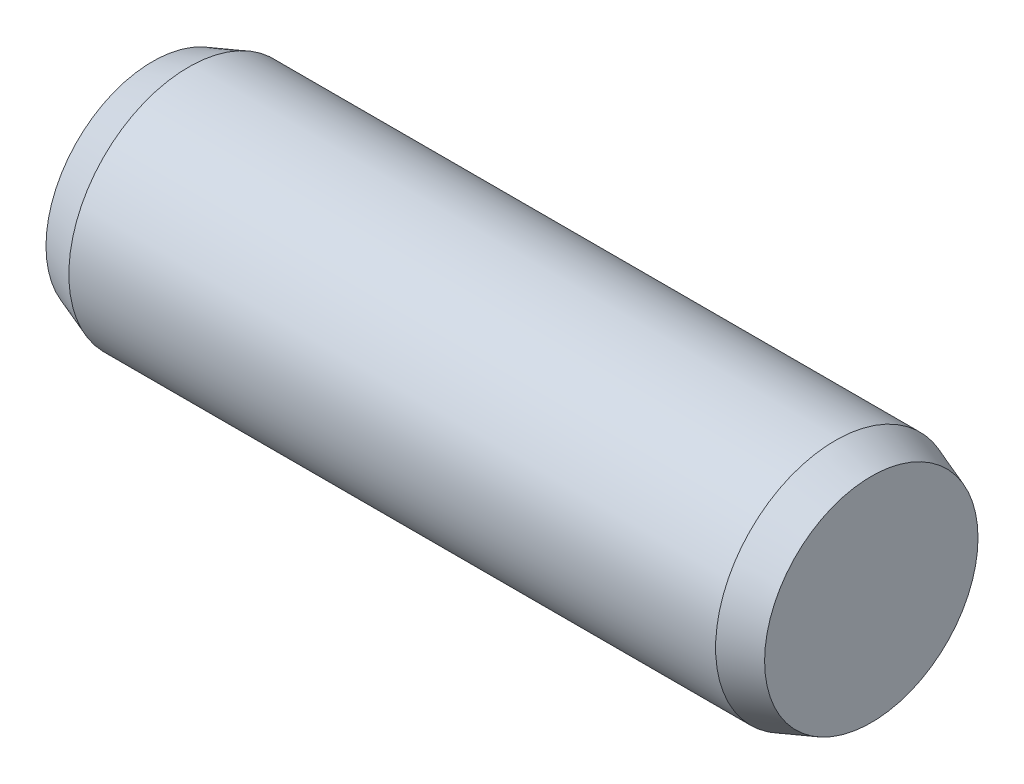
from build123d import *


with BuildPart() as part:
    # Sketch1 → Revolve1 (revolve)
    with BuildSketch(Plane.XY):
        Polygon((-3, 0.89090893), (-3, 0), (3, 0), (3, 0.89090893), (2.7, 1.0001), (-2.7, 1.0001), align=None)
    revolve(axis=Axis((-3, 0, 0), (1, 0, 0)))


solid = part.part
